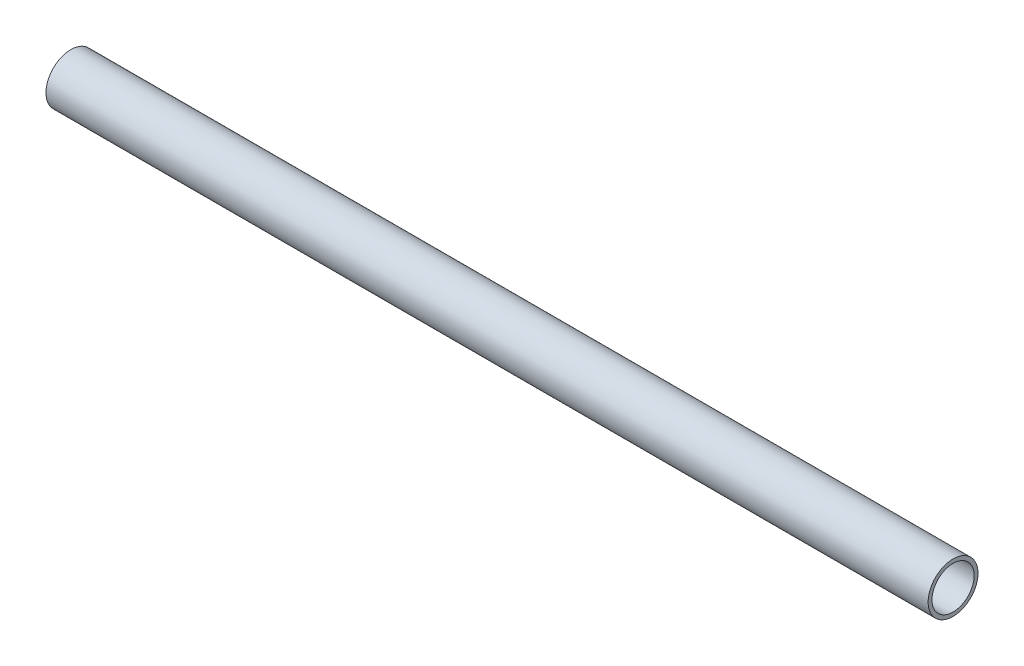
from build123d import *

# Parameters (mm, degrees)
SKETCH_1_R          = 13
SKETCH_1_R_2        = 11
EXTRUDE_1_DEPTH     = 460
SKETCH_2_R          = 2
SKETCH_2_R_2        = 2.5
CUT_EXTRUDE_1_DEPTH = 14


with BuildPart() as part:
    # 草图1 → 凸台-拉伸1 (new body)
    with BuildSketch(Plane(origin=(0, 0, 0), x_dir=(0, 0, -1), z_dir=(1, 0, 0))):
        Circle(SKETCH_1_R)
        Circle(SKETCH_1_R_2, mode=Mode.SUBTRACT)
    extrude(amount=EXTRUDE_1_DEPTH)

    # 草图2 → 切除-拉伸1 (cut, through all)
    with BuildSketch(Plane.XY):
        with Locations((21, 0)):
            Circle(SKETCH_2_R)
        with Locations((445, 0)):
            Circle(SKETCH_2_R_2)
    extrude(amount=-CUT_EXTRUDE_1_DEPTH, mode=Mode.SUBTRACT)


solid = part.part
